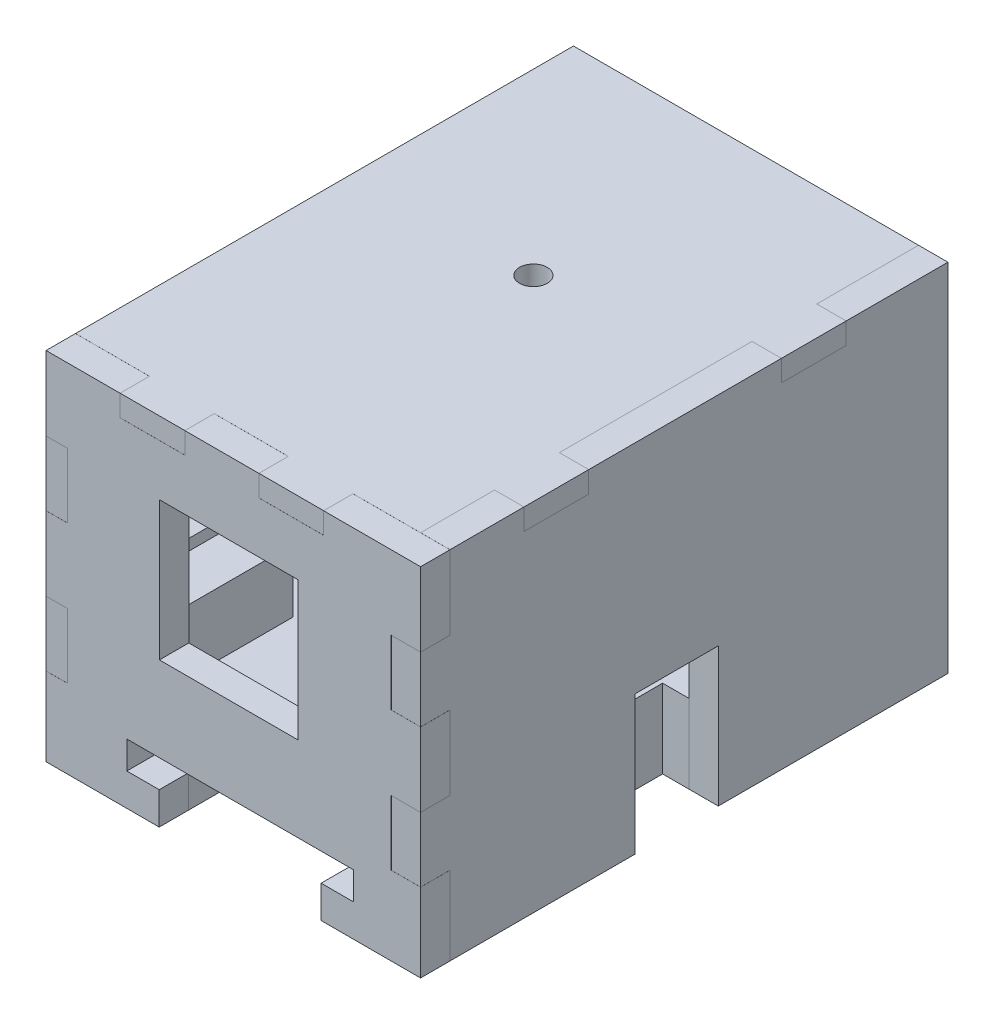
from build123d import *

# Parameters (mm, degrees)
SKETCH1_W                    = 53.825
SKETCH1_H                    = 38.5
MAIN_EXTRUDE_DEPTH           = 2.3
WALLS_DEPTH                  = 35
SKETCH36_W                   = 7
SKETCH36_H                   = 2.3
SKETCH36_W_2                 = 2.3
SKETCH36_H_2                 = 7
PUZZLE_MAIN_WALLS_DEPTH      = 3.175
SKETCH25_W                   = 10.403042977
SKETCH25_H                   = 6.605151166
WIRE_HOLE_DEPTH              = 3.3
SKETCH19_W                   = 6.5
SKETCH19_H                   = 15.2
SKETCH19_W_2                 = 6
IR_MOUNT_DEPTH               = 7
MAGNET_MOUNT_HOLE_DEPTH      = 51.83
SKETCH40_R                   = 1.5
LED_SPACE_DEPTH              = 3
SKETCH42_W                   = 7
SKETCH42_H                   = 2.3
BOSS_EXTRUDE15_DEPTH         = 3.175
SKETCH44_W                   = 6
SKETCH44_H                   = 15.2
SKETCH44_W_2                 = 6.5
BOSS_EXTRUDE16_DEPTH         = 6
SKETCH45_W                   = 5
SKETCH45_H                   = 5
IR_PLACEMENT_DEPTH           = 15.2
SKETCH47_R                   = 2.5
CUT_EXTRUDE2_DEPTH           = 2
SKETCH48_W                   = 7
SKETCH48_H                   = 9
CUT_EXTRUDE3_DEPTH           = 15
SKETCH6_W                    = 40.48
SKETCH6_H                    = 38.5
FRONT_LID_DEPTH              = 3.175
NOSEPOKE_HOLE_DEPTH          = 3.175
SKETCH34_W                   = 2.3
SKETCH34_H                   = 7
SKETCH34_W_2                 = 7
SKETCH34_H_2                 = 2.3
SKETCH34_W_3                 = 3.175
PUZZLE_FRONT_LID_DEPTH       = 3.175
MAGNET_MOUNT_FRONT_LID_DEPTH = 3.175
SKETCH20_W                   = 53.825
SKETCH20_H                   = 38.5
SIDE_MAIN_DEPTH              = 3.175
SKETCH37_W                   = 3.175
SKETCH37_H                   = 7
PUZZLE_SIDE_PART_DEPTH       = 3.175
SKETCH41_W                   = 7
SKETCH41_H                   = 2.3
CUT_EXTRUDE1_DEPTH           = 3.175
SKETCH49_W                   = 7
SKETCH49_H                   = 9
CUT_EXTRUDE4_DEPTH           = 15


with BuildPart() as part:
    # Sketch1 → main extrude (new body)
    with BuildSketch(Plane(origin=(0, 0, 0), x_dir=(0, 0, -1), z_dir=(1, 0, 0))):
        with Locations((-26.9125, 21.443980352)):
            Rectangle(SKETCH1_W, SKETCH1_H)
    extrude(amount=MAIN_EXTRUDE_DEPTH)

    # Sketch3 → walls (add)
    with BuildSketch(Plane(origin=(2.3, 0, 0), x_dir=(0, 0, -1), z_dir=(1, 0, 0))):
        Polygon((-2.3, 38.393980352), (-2.3, 10.693980352), (-53.825, 10.693980352), (-53.825, 2.193980352), (0, 2.193980352), (0, 40.693980352), (-53.825, 40.693980352), (-53.825, 38.393980352), align=None)
    extrude(amount=WALLS_DEPTH)

    # Sketch36 → Puzzle (main walls) (add)
    with BuildSketch(Plane.XY.offset(53.825)):
        with Locations((11.5, 39.543980352)):
            Rectangle(SKETCH36_W, SKETCH36_H)
        with Locations((26.5, 39.543980352)):
            Rectangle(SKETCH36_W, SKETCH36_H)
        with Locations((1.15, 29.193980352)):
            Rectangle(SKETCH36_W_2, SKETCH36_H_2)
        with Locations((1.15, 14.193980352)):
            Rectangle(SKETCH36_W_2, SKETCH36_H_2)
    extrude(amount=PUZZLE_MAIN_WALLS_DEPTH)

    # Sketch25 → Wire Hole (cut, through all)
    with BuildSketch(Plane.XY.offset(2.3)):
        with Locations((7.501521489, 13.996555935)):
            Rectangle(SKETCH25_W, SKETCH25_H)
    extrude(amount=-WIRE_HOLE_DEPTH, mode=Mode.SUBTRACT)

    # Sketch19 → IR mount (add)
    with BuildSketch(Plane(origin=(0, 10.693980352, 0), x_dir=(1, 0, 0), z_dir=(0, 1, 0))):
        with Locations((34.05, -46.225)):
            Rectangle(SKETCH19_W, SKETCH19_H)
        with Locations((5.3, -46.225)):
            Rectangle(SKETCH19_W_2, SKETCH19_H)
    extrude(amount=IR_MOUNT_DEPTH)

    # Sketch24 → Magnet Mount Hole (cut)
    with BuildSketch(Plane.XY.offset(53.83)):
        Polygon((12.23, 2.193980352), (29.73, 2.193980352), (29.73, 5.693980352), (33.23, 5.693980352), (33.23, 8.693980352), (8.73, 8.693980352), (8.73, 5.693980352), (12.23, 5.693980352), align=None)
    extrude(amount=-MAGNET_MOUNT_HOLE_DEPTH, mode=Mode.SUBTRACT)

    # Sketch40 → LED Space (cut)
    with BuildSketch(Plane(origin=(0, 40.693980352, 0), x_dir=(1, 0, 0), z_dir=(0, 1, 0))):
        with Locations((19.3, -23.632870167)):
            Circle(SKETCH40_R)
    extrude(amount=-LED_SPACE_DEPTH, mode=Mode.SUBTRACT)

    # Sketch42 → Boss-Extrude15 (add)
    with BuildSketch(Plane(origin=(37.3, 0, 0), x_dir=(0, 0, -1), z_dir=(1, 0, 0))):
        with Locations((-42.325, 39.543980352)):
            Rectangle(SKETCH42_W, SKETCH42_H)
        with Locations((-14.5, 39.543980352)):
            Rectangle(SKETCH42_W, SKETCH42_H)
    extrude(amount=BOSS_EXTRUDE15_DEPTH)

    # Sketch44 → Boss-Extrude16 (add)
    with BuildSketch(Plane(origin=(0, 17.693980352, 0), x_dir=(1, 0, 0), z_dir=(0, 1, 0))):
        with Locations((5.3, -46.225)):
            Rectangle(SKETCH44_W, SKETCH44_H)
        with Locations((34.05, -46.225)):
            Rectangle(SKETCH44_W_2, SKETCH44_H)
    extrude(amount=BOSS_EXTRUDE16_DEPTH)

    # Sketch45 → IR placement (cut)
    with BuildSketch(Plane.XY.offset(53.825)):
        with Locations((33.3, 19.993980352)):
            Rectangle(SKETCH45_W, SKETCH45_H)
        with Locations((5.8, 19.993980352)):
            Rectangle(SKETCH45_W, SKETCH45_H)
    extrude(amount=-IR_PLACEMENT_DEPTH, mode=Mode.SUBTRACT)

    # Sketch47 → Cut-Extrude2 (cut)
    with BuildSketch(Plane(origin=(0, 0, 0), x_dir=(-1, 0, 0), z_dir=(0, 0, -1))):
        with Locations((-21.018982331, 5.262699137)):
            Circle(SKETCH47_R)
    extrude(amount=-CUT_EXTRUDE2_DEPTH, mode=Mode.SUBTRACT)

    # Sketch48 → Cut-Extrude3 (cut)
    with BuildSketch(Plane.XZ.offset(-2.193980352)):
        with Locations((3.5, 29.325)):
            Rectangle(SKETCH48_W, SKETCH48_H)
        with Locations((37.962462444, 29.325)):
            Rectangle(SKETCH48_W, SKETCH48_H)
    extrude(amount=-CUT_EXTRUDE3_DEPTH, mode=Mode.SUBTRACT)


with BuildPart() as body_2:
    # Sketch6 → front lid (new body)
    with BuildSketch(Plane.XY.offset(53.83)):
        with Locations((20.24, 21.443980352)):
            Rectangle(SKETCH6_W, SKETCH6_H)
    extrude(amount=FRONT_LID_DEPTH)

    # Sketch7 → nosepoke hole (cut)
    with BuildSketch(Plane.XY.offset(57.005)):
        Polygon((19.75, 17.853980352), (27.25, 17.853980352), (27.25, 32.853980352), (12.25, 32.853980352), (12.25, 17.853980352), align=None)
    extrude(amount=-NOSEPOKE_HOLE_DEPTH, mode=Mode.SUBTRACT)

    # Sketch34 → Puzzle (Front Lid) (cut)
    with BuildSketch(Plane.XY.offset(57.005)):
        with Locations((1.15, 29.193980352)):
            Rectangle(SKETCH34_W, SKETCH34_H)
        with Locations((11.5, 39.543980352)):
            Rectangle(SKETCH34_W_2, SKETCH34_H_2)
        with Locations((26.5, 39.543980352)):
            Rectangle(SKETCH34_W_2, SKETCH34_H_2)
        with Locations((1.15, 14.193980352)):
            Rectangle(SKETCH34_W, SKETCH34_H)
        with Locations((38.8925, 29.193980352)):
            Rectangle(SKETCH34_W_3, SKETCH34_H)
        with Locations((38.8925, 14.193980352)):
            Rectangle(SKETCH34_W_3, SKETCH34_H)
    extrude(amount=-PUZZLE_FRONT_LID_DEPTH, mode=Mode.SUBTRACT)

    # Sketch46 → magnet mount front lid (cut)
    with BuildSketch(Plane.XY.offset(57.005)):
        Polygon((12.23, 2.193980352), (29.73, 2.193980352), (29.73, 5.693980352), (33.23, 5.693980352), (33.23, 8.693980352), (8.73, 8.693980352), (8.73, 5.693980352), (12.23, 5.693980352), align=None)
    extrude(amount=-MAGNET_MOUNT_FRONT_LID_DEPTH, mode=Mode.SUBTRACT)


with BuildPart() as body_3:
    # Sketch20 → Side main (new body)
    with BuildSketch(Plane(origin=(37.3, 0, 0), x_dir=(0, 0, -1), z_dir=(1, 0, 0))):
        with Locations((-26.9125, 21.443980352)):
            Rectangle(SKETCH20_W, SKETCH20_H)
    extrude(amount=SIDE_MAIN_DEPTH)

    # Sketch37 → Puzzle (side part) (add)
    with BuildSketch(Plane.XY.offset(53.825)):
        with Locations((38.8875, 29.193980352)):
            Rectangle(SKETCH37_W, SKETCH37_H)
        with Locations((38.8875, 14.193980352)):
            Rectangle(SKETCH37_W, SKETCH37_H)
    extrude(amount=PUZZLE_SIDE_PART_DEPTH)

    # Sketch41 → Cut-Extrude1 (cut)
    with BuildSketch(Plane(origin=(40.475, 0, 0), x_dir=(0, 0, -1), z_dir=(1, 0, 0))):
        with Locations((-42.325, 39.543980352)):
            Rectangle(SKETCH41_W, SKETCH41_H)
        with Locations((-14.5, 39.543980352)):
            Rectangle(SKETCH41_W, SKETCH41_H)
    extrude(amount=-CUT_EXTRUDE1_DEPTH, mode=Mode.SUBTRACT)

    # Sketch49 → Cut-Extrude4 (cut)
    with BuildSketch(Plane.XZ.offset(-2.193980352)):
        with Locations((36.975, 29.325)):
            Rectangle(SKETCH49_W, SKETCH49_H)
    extrude(amount=-CUT_EXTRUDE4_DEPTH, mode=Mode.SUBTRACT)


solid = Compound([part.part, body_2.part, body_3.part])
